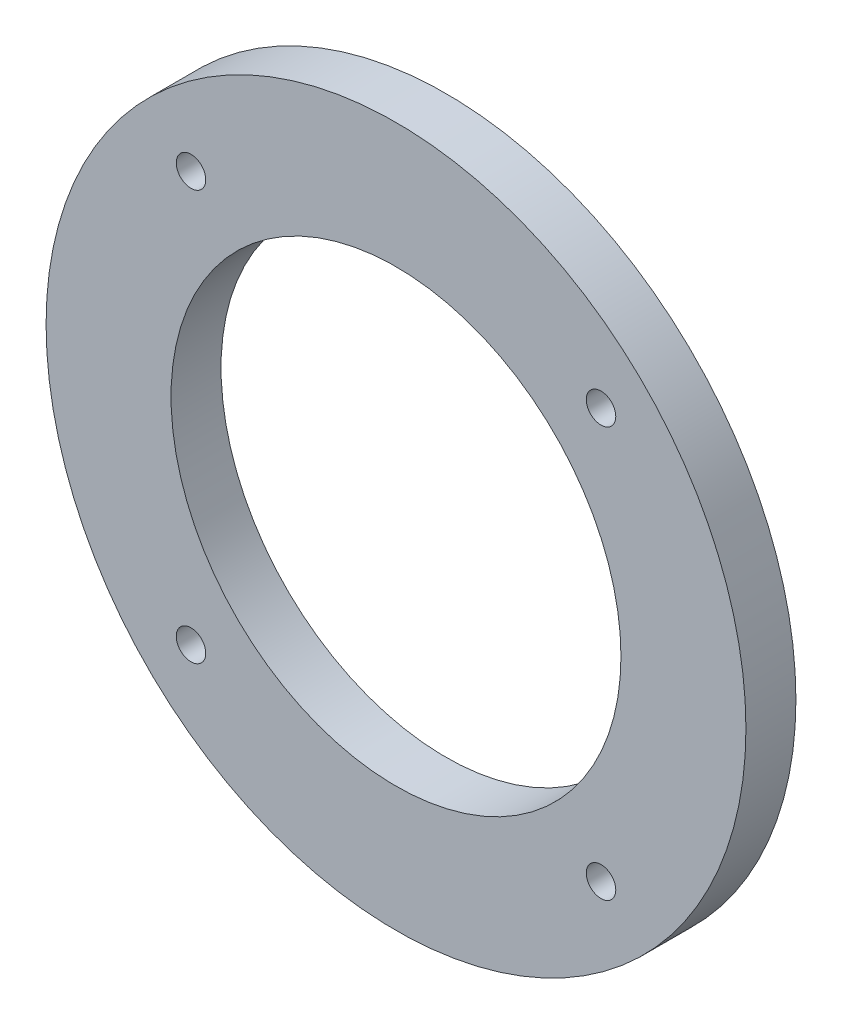
from build123d import *

# Parameters (mm, degrees)
SKETCH1_R           = 35
SKETCH1_R_2         = 22.5
SKETCH1_R_3         = 1.475
BOSS_EXTRUDE1_DEPTH = 5


with BuildPart() as part:
    # Sketch1 → Boss-Extrude1 (new body)
    with BuildSketch(Plane.XY):
        Circle(SKETCH1_R)
        Circle(SKETCH1_R_2, mode=Mode.SUBTRACT)
        with Locations((-20.506096654, 20.506096654)):
            Circle(SKETCH1_R_3, mode=Mode.SUBTRACT)
        with Locations((20.506096654, 20.506096654)):
            Circle(SKETCH1_R_3, mode=Mode.SUBTRACT)
        with Locations((20.506096654, -20.506096654)):
            Circle(SKETCH1_R_3, mode=Mode.SUBTRACT)
        with Locations((-20.506096654, -20.506096654)):
            Circle(SKETCH1_R_3, mode=Mode.SUBTRACT)
    extrude(amount=BOSS_EXTRUDE1_DEPTH)


solid = part.part
